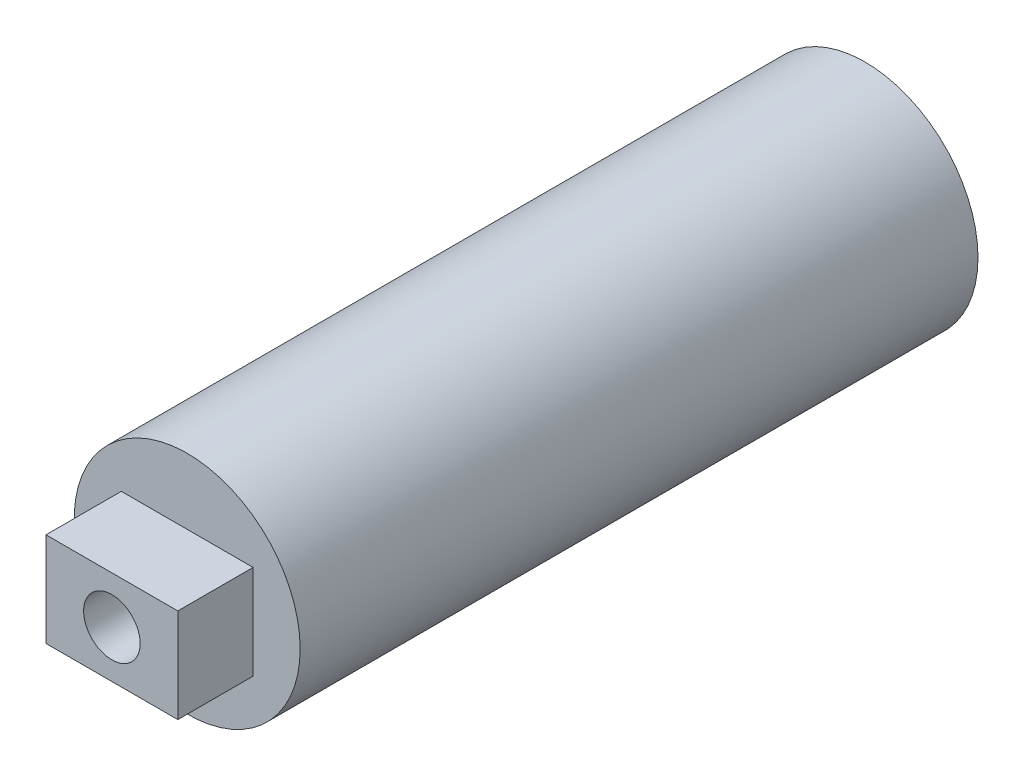
from build123d import *

# Parameters (mm, degrees)
SKETCH9_R            = 30
BOSS_EXTRUDE11_DEPTH = 180
SKETCH10_W           = 35
SKETCH10_H           = 25
BOSS_EXTRUDE12_DEPTH = 20
SKETCH11_R           = 7.5
CUT_EXTRUDE2_DEPTH   = 201
SHELL1_T             = -1


with BuildPart() as part:
    # Sketch9 → Boss-Extrude11 (new body)
    with BuildSketch(Plane.XY):
        Circle(SKETCH9_R)
    extrude(amount=BOSS_EXTRUDE11_DEPTH)

    # Sketch10 → Boss-Extrude12 (add)
    with BuildSketch(Plane.XY.offset(180)):
        Rectangle(SKETCH10_W, SKETCH10_H)
    extrude(amount=BOSS_EXTRUDE12_DEPTH)

    # Sketch11 → Cut-Extrude2 (cut, through all)
    with BuildSketch(Plane.XY.offset(200)):
        Circle(SKETCH11_R)
    extrude(amount=-CUT_EXTRUDE2_DEPTH, mode=Mode.SUBTRACT)

    # Shell1
    shell1_openings = [part.faces().sort_by_distance(p)[0] for p in [
        (7.5, 0, 0),
    ]]
    offset(amount=SHELL1_T, openings=shell1_openings, kind=Kind.INTERSECTION)


solid = part.part
